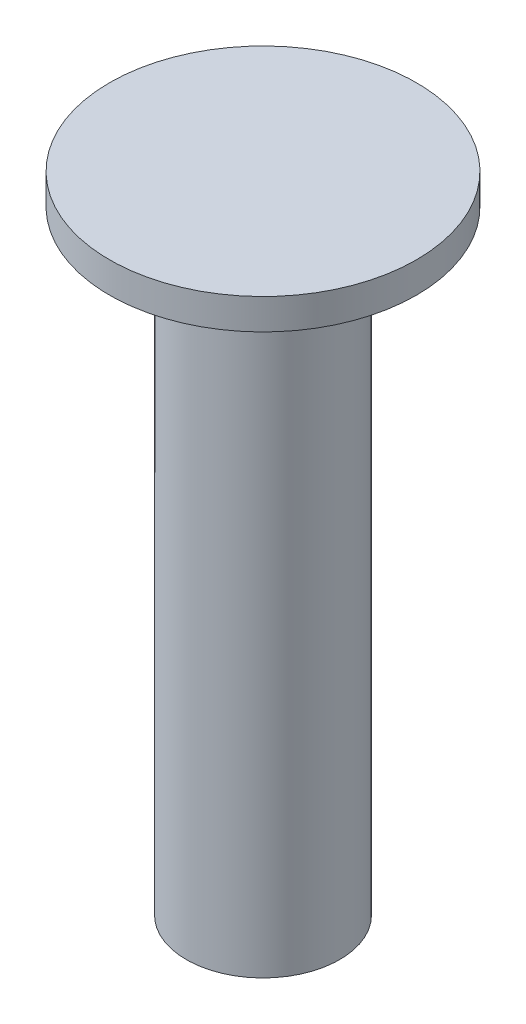
from build123d import *


with BuildPart() as part:
    # Esquisse1 → Révolution1 (revolve)
    with BuildSketch(Plane.XY):
        Polygon((0, 0), (-2.5, 0), (-2.5, 20), (-5, 20), (-5, 21), (0, 21), align=None)
    revolve(axis=Axis((0, 21, 0), (0, -1, 0)))


solid = part.part
